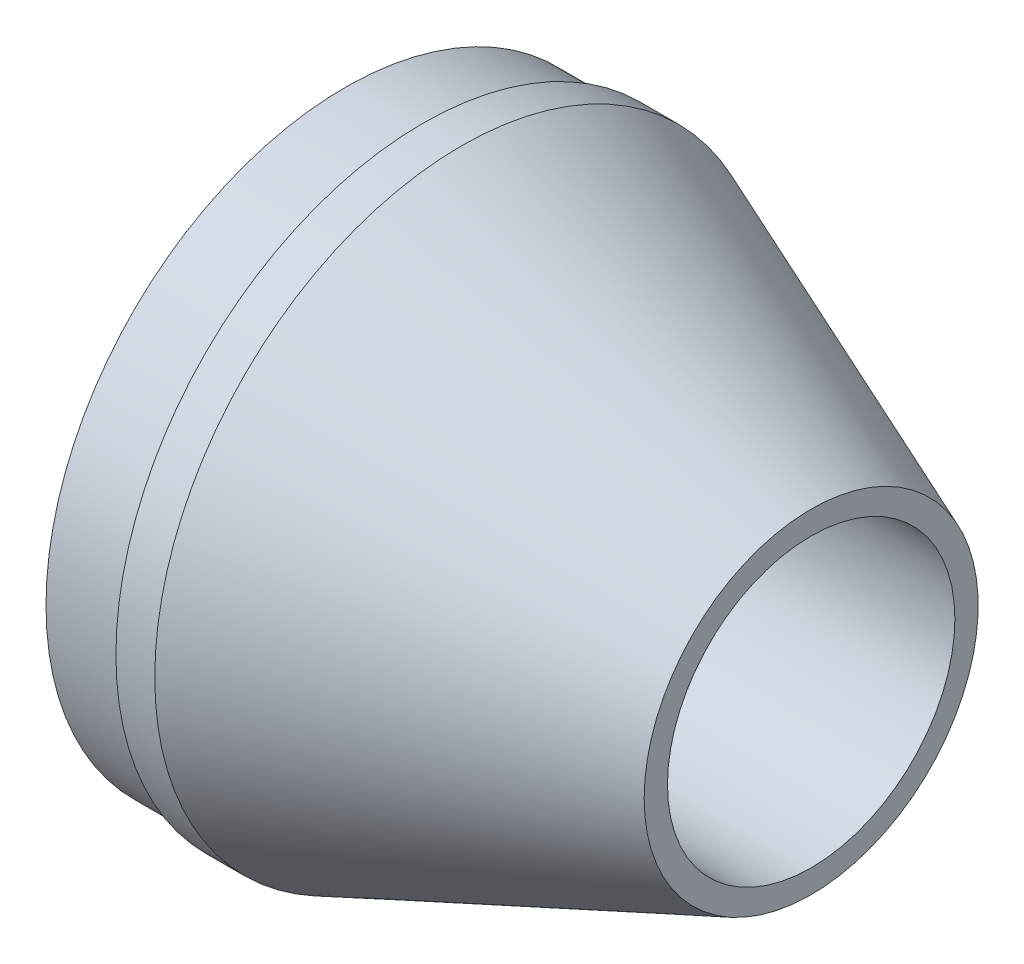
from build123d import *


with BuildPart() as part:
    # Esquisse1 → Révolution1 (revolve)
    with BuildSketch(Plane.XY, mode=Mode.PRIVATE) as r_volution1_sk:
        Polygon((-28.565758671, 25.213681359), (-18.565758671, 25.213681359), (-18.565758671, 26.213681359), (-13.565758671, 26.213681359), (31.434241329, 8.213681359), (31.434241329, 5.213681359), (-15.565758671, 5.213681359), (-15.565758671, 7.213681359), (-28.565758671, 7.213681359), align=None)
    revolve(r_volution1_sk.sketch.rotate(Axis((-43.545779604, -13.286318641, 0), (1, 0, 0)), 90), axis=Axis((-43.545779604, -13.286318641, 0), (1, 0, 0)))  # turned: the seam where the file's is


solid = part.part
